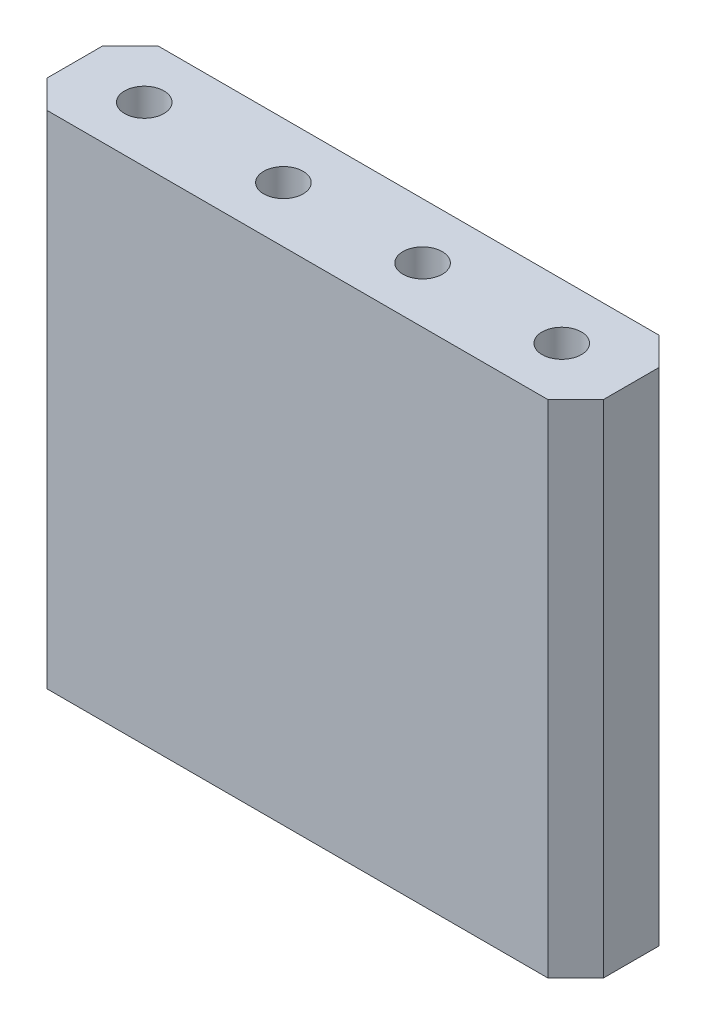
from build123d import *

# Parameters (mm, degrees)
SKETCH_1_W      = 10
SKETCH_1_H      = 2
SKETCH_1_W_2    = 0.5
SKETCH_1_H_2    = 0.5
EXTRUDE_1_DEPTH = 7
SKETCH_2_W      = 10
SKETCH_2_H      = 2
SKETCH_2_R      = 0.353553391
EXTRUDE_2_DEPTH = 2
CHAMFER_1_SIZE  = 0.5


with BuildPart() as part:
    # Эскиз1 → Бобышка-Вытянуть1 (new body)
    with BuildSketch(Plane(origin=(0, 0, 0), x_dir=(1, 0, 0), z_dir=(0, 1, 0))):
        Rectangle(SKETCH_1_W, SKETCH_1_H)
        with Locations((-3.75, 0)):
            Rectangle(SKETCH_1_W_2, SKETCH_1_H_2, mode=Mode.SUBTRACT)
        with Locations((3.75, 0)):
            Rectangle(SKETCH_1_W_2, SKETCH_1_H_2, mode=Mode.SUBTRACT)
        with Locations((-1.25, 0)):
            Rectangle(SKETCH_1_W_2, SKETCH_1_H_2, mode=Mode.SUBTRACT)
        with Locations((1.25, 0)):
            Rectangle(SKETCH_1_W_2, SKETCH_1_H_2, mode=Mode.SUBTRACT)
    extrude(amount=EXTRUDE_1_DEPTH)

    # Эскиз2 → Бобышка-Вытянуть2 (add)
    with BuildSketch(Plane(origin=(0, 7, 0), x_dir=(1, 0, 0), z_dir=(0, 1, 0))):
        Rectangle(SKETCH_2_W, SKETCH_2_H)
        with Locations((-3.75, 0)):
            Circle(SKETCH_2_R, mode=Mode.SUBTRACT)
        with Locations((-1.25, 0)):
            Circle(SKETCH_2_R, mode=Mode.SUBTRACT)
        with Locations((1.25, 0)):
            Circle(SKETCH_2_R, mode=Mode.SUBTRACT)
        with Locations((3.75, 0)):
            Circle(SKETCH_2_R, mode=Mode.SUBTRACT)
    extrude(amount=EXTRUDE_2_DEPTH)

    # Фаска1
    chamfer_1_edges = [part.edges().sort_by_distance(p)[0] for p in [
        (5, 4.5, 1),
        (-5, 4.5, 1),
        (-5, 4.5, -1),
        (5, 4.5, -1),
    ]]
    chamfer(chamfer_1_edges, length=CHAMFER_1_SIZE)


solid = part.part
